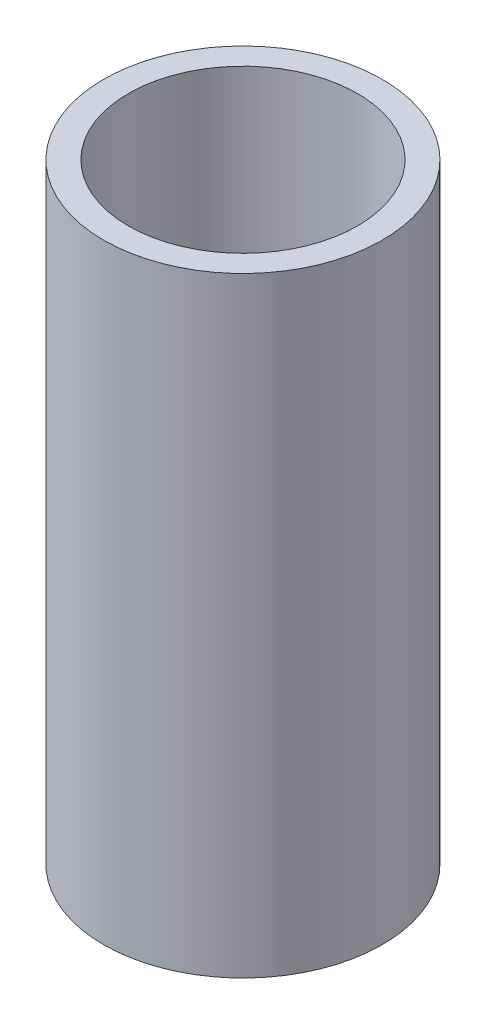
from build123d import *

# Parameters (mm, degrees)
SKETCH1_R           = 39.5
BOSS_EXTRUDE1_DEPTH = 173
SKETCH2_R           = 32.5
CUT_EXTRUDE1_DEPTH  = 125


with BuildPart() as part:
    # Sketch1 → Boss-Extrude1 (new body)
    with BuildSketch(Plane(origin=(0, 0, 0), x_dir=(1, 0, 0), z_dir=(0, 1, 0))):
        Circle(SKETCH1_R)
    extrude(amount=BOSS_EXTRUDE1_DEPTH)

    # Sketch2 → Cut-Extrude1 (cut)
    with BuildSketch(Plane(origin=(0, 173, 0), x_dir=(1, 0, 0), z_dir=(0, 1, 0))):
        Circle(SKETCH2_R)
    extrude(amount=-CUT_EXTRUDE1_DEPTH, mode=Mode.SUBTRACT)


solid = part.part
